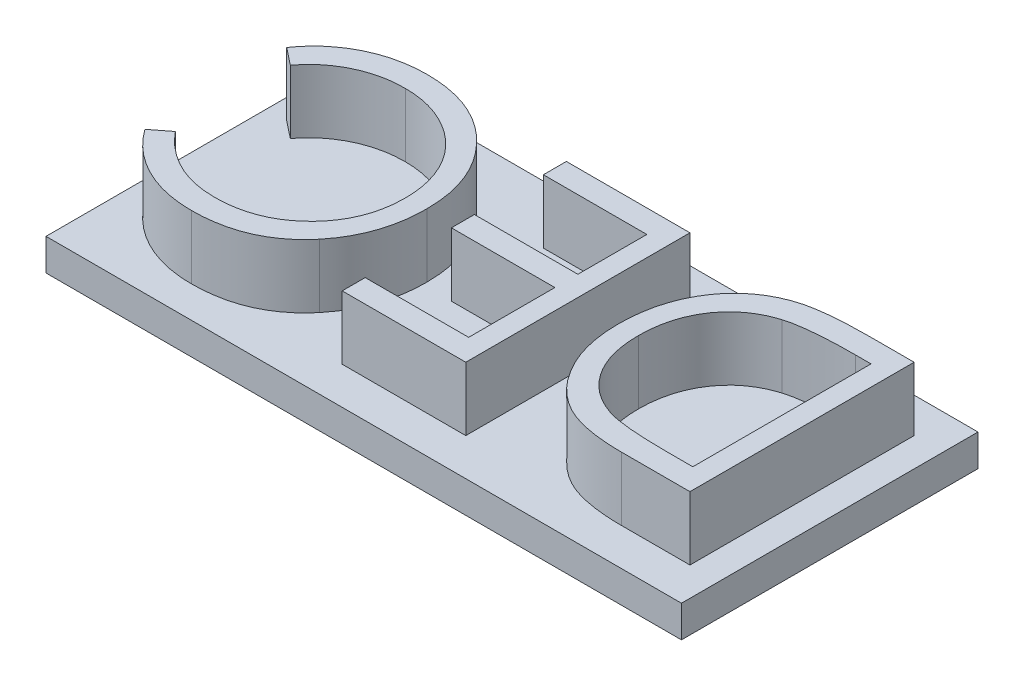
from build123d import *

# Parameters (mm, degrees)
SKETCH1_W           = 15
SKETCH1_H           = 7
BOSS_EXTRUDE1_DEPTH = 0.75
BOSS_EXTRUDE2_DEPTH = 1.5


with BuildPart() as part:
    # Sketch1 → Boss-Extrude1 (new body)
    with BuildSketch(Plane(origin=(0, 0, 0), x_dir=(1, 0, 0), z_dir=(0, 1, 0))):
        Rectangle(SKETCH1_W, SKETCH1_H)
    extrude(amount=BOSS_EXTRUDE1_DEPTH)

    # Sketch2 → Boss-Extrude2 (add)
    with BuildSketch(Plane(origin=(0, 0.75, 0), x_dir=(1, 0, 0), z_dir=(0, 1, 0))):
        with BuildLine():
            Line((6.819807811, -2.619170324), (6.819807811, 2.672496343))
            Line((6.819807811, 2.672496343), (5.767198636, 2.672496343))
            add(Edge.make_bspline(
                [(5.767198636, 2.672496343), (5.675676514, 2.671828776), (5.498951689, 2.670539735), (5.243729806, 2.662334987), (5.007894011, 2.647885338), (4.791573229, 2.626555862), (4.594400699, 2.600948259), (4.416776216, 2.568123539), (4.258546118, 2.5301148), (4.161410306, 2.497192755), (4.115672862, 2.481691054)],
                knots=[0, 0, 0, 0, 0.000274566, 0.000530174, 0.000765968, 0.000983251, 0.001182189, 0.001362238, 0.001524979, 0.001669797, 0.001669797, 0.001669797, 0.001669797], degree=3))
            add(Edge.make_bspline(
                [(4.115672862, 2.481691054), (4.055520422, 2.458319777), (3.936272744, 2.411987981), (3.76627177, 2.32521795), (3.60613388, 2.226589303), (3.455207371, 2.11627488), (3.317056863, 1.991131144), (3.186024775, 1.856518497), (3.068014108, 1.707073142), (2.958461251, 1.547424448), (2.86166046, 1.376929879), (2.776022147, 1.198397052), (2.705478495, 1.011225192), (2.646833603, 0.81647182), (2.601439929, 0.613449091), (2.568587015, 0.402447458), (2.549360783, 0.183554722), (2.546978409, 0.035181062), (2.54576935, -0.040118842)],
                knots=[0, 0, 0, 0, 0.000193501, 0.000383601, 0.000571589, 0.000757312, 0.000943497, 0.001130173, 0.001320223, 0.00151398, 0.001710543, 0.001907788, 0.002107415, 0.002309972, 0.002517505, 0.002730995, 0.002950193, 0.003176069, 0.003176069, 0.003176069, 0.003176069], degree=3))
            add(Edge.make_bspline(
                [(2.54576935, -0.040118842), (2.546886805, -0.105509325), (2.549088381, -0.234339574), (2.563530317, -0.424552304), (2.590623148, -0.608458708), (2.62649015, -0.786499571), (2.671631565, -0.959313486), (2.729422293, -1.125382844), (2.795848778, -1.286165643), (2.873506623, -1.439484576), (2.958757925, -1.584822342), (3.050608363, -1.721328393), (3.147139687, -1.84876971), (3.252409588, -1.964689498), (3.36202299, -2.072282743), (3.479281975, -2.168598215), (3.601571669, -2.256139355), (3.730944304, -2.334410146), (3.870381936, -2.403212936), (4.022430082, -2.461056213), (4.187708678, -2.509630202), (4.365884831, -2.549448147), (4.556931607, -2.581405265), (4.761191642, -2.602882483), (4.978683405, -2.617246889), (5.128329305, -2.618516561), (5.205383065, -2.619170324)],
                knots=[0, 0, 0, 0, 0.000196177, 0.000386502, 0.000571792, 0.000753487, 0.000931158, 0.001107152, 0.001280589, 0.001452673, 0.001622295, 0.001785759, 0.001946045, 0.002101421, 0.002255096, 0.002406428, 0.002556148, 0.002705946, 0.002859544, 0.003021954, 0.003193341, 0.003375925, 0.003569362, 0.003774102, 0.003991844, 0.004222969, 0.004222969, 0.004222969, 0.004222969], degree=3))
            Line((5.205383065, -2.619170324), (6.819807811, -2.619170324))
        make_face()
        with BuildLine():
            Line((6.344914649, -2.076435281), (5.749178137, -2.076435281))
            add(Edge.make_bspline(
                [(5.749178137, -2.076435281), (5.663664961, -2.076061495), (5.499326628, -2.075343158), (5.262884722, -2.069001075), (5.046570259, -2.058628627), (4.850692286, -2.044252646), (4.675728258, -2.025101342), (4.520996704, -2.003490784), (4.386529759, -1.977125293), (4.304923513, -1.952963669), (4.267257063, -1.94181155)],
                knots=[0, 0, 0, 0, 0.000256536, 0.000493008, 0.000709514, 0.00090618, 0.001082122, 0.00123743, 0.001374846, 0.001492643, 0.001492643, 0.001492643, 0.001492643], degree=3))
            add(Edge.make_bspline(
                [(4.267257063, -1.94181155), (4.220004494, -1.924808365), (4.126623293, -1.89120643), (3.992159255, -1.829626807), (3.866233732, -1.756929143), (3.746510039, -1.676738186), (3.63604659, -1.585126105), (3.534383512, -1.483367767), (3.437827482, -1.374435663), (3.351674731, -1.25412773), (3.272929408, -1.12680626), (3.206415933, -0.991094264), (3.148879988, -0.849466214), (3.100710183, -0.70090125), (3.065136032, -0.544708676), (3.040159943, -0.382075273), (3.023469716, -0.212895273), (3.021610364, -0.097754665), (3.020662512, -0.039058812)],
                knots=[0, 0, 0, 0, 0.000150617, 0.000297652, 0.000442938, 0.000586415, 0.000729468, 0.000872634, 0.001017626, 0.001165625, 0.001315973, 0.001466251, 0.001618412, 0.001774294, 0.001934232, 0.0020984, 0.002267693, 0.002443738, 0.002443738, 0.002443738, 0.002443738], degree=3))
            add(Edge.make_bspline(
                [(3.020662512, -0.039058812), (3.021571644, 0.022814678), (3.023357134, 0.144331152), (3.040625249, 0.322886563), (3.069445499, 0.494211278), (3.108395651, 0.659113256), (3.159081684, 0.817357004), (3.222306362, 0.968334721), (3.295020744, 1.113142154), (3.380233021, 1.249488267), (3.47406561, 1.378091503), (3.578324846, 1.495979015), (3.691454535, 1.603318562), (3.812119189, 1.701847044), (3.943696907, 1.787213372), (4.08241153, 1.864171403), (4.230986037, 1.929181806), (4.334455368, 1.963775855), (4.387040383, 1.981357187)],
                knots=[0, 0, 0, 0, 0.000185581, 0.000364472, 0.00053752, 0.00070644, 0.000872378, 0.001035378, 0.001197035, 0.00135794, 0.001517163, 0.001674123, 0.001829326, 0.001984612, 0.002140728, 0.002299184, 0.002460092, 0.002626378, 0.002626378, 0.002626378, 0.002626378], degree=3))
            add(Edge.make_bspline(
                [(4.387040383, 1.981357187), (4.4303486, 1.99365159), (4.522876967, 2.019918686), (4.673766458, 2.047958695), (4.84381209, 2.07344535), (5.033332583, 2.094469567), (5.24232195, 2.109784544), (5.470642446, 2.121249788), (5.71873797, 2.128962966), (5.89086249, 2.129488392), (5.980264542, 2.1297613)],
                knots=[0, 0, 0, 0, 0.000134995, 0.000288417, 0.000459919, 0.000650845, 0.000860276, 0.00108848, 0.001336638, 0.001604834, 0.001604834, 0.001604834, 0.001604834], degree=3))
            Line((5.980264542, 2.1297613), (6.344914649, 2.1297613))
            Line((6.344914649, 2.1297613), (6.344914649, -2.076435281))
        make_face(mode=Mode.SUBTRACT)
        Polygon((1.528141144, 2.672496343), (-1.38905971, 2.672496343), (-1.38905971, 2.1297613), (1.053247982, 2.1297613), (1.053247982, 0.501556172), (-1.38905971, 0.501556172), (-1.38905971, -0.041178871), (1.053247982, -0.041178871), (1.053247982, -2.076435281), (-1.38905971, -2.076435281), (-1.38905971, -2.619170324), (1.528141144, -2.619170324), align=None)
        with BuildLine():
            Line((-7.019935779, 1.70150943), (-6.616064585, 1.383500616))
            add(Edge.make_bspline(
                [(-6.616064585, 1.383500616), (-6.587842278, 1.418817444), (-6.531821719, 1.488920447), (-6.441322073, 1.587470349), (-6.346873213, 1.679851962), (-6.248518796, 1.766027962), (-6.145242016, 1.844141744), (-6.038858354, 1.917090757), (-5.927438747, 1.98253946), (-5.77343951, 2.061618059), (-5.572029164, 2.144649694), (-5.318128514, 2.213899211), (-5.053017042, 2.258266678), (-4.872143037, 2.263023995), (-4.780093698, 2.265445061)],
                knots=[0, 0, 0, 0, 0.000135593, 0.000269148, 0.000401078, 0.00053181, 0.000661138, 0.000789327, 0.000918586, 0.001048486, 0.001308524, 0.001570332, 0.001836616, 0.002112568, 0.002112568, 0.002112568, 0.002112568], degree=3))
            add(Edge.make_bspline(
                [(-4.780093698, 2.265445061), (-4.729169218, 2.26484293), (-4.628155316, 2.263648543), (-4.478498594, 2.247611115), (-4.33180866, 2.224877041), (-4.188013274, 2.191794439), (-4.047044592, 2.148838443), (-3.907844832, 2.099000634), (-3.773076752, 2.036131958), (-3.640833869, 1.967126683), (-3.514336135, 1.888744391), (-3.394227937, 1.803907186), (-3.281518189, 1.71263302), (-3.176402064, 1.614497752), (-3.077468936, 1.511142101), (-2.987070316, 1.399741007), (-2.903450073, 1.282795763), (-2.82830749, 1.159175941), (-2.760176961, 1.031427766), (-2.702046361, 0.898790003), (-2.652887392, 0.762055268), (-2.613042545, 0.621355767), (-2.580765749, 0.477050029), (-2.558943085, 0.328587322), (-2.544472559, 0.176416393), (-2.543075911, 0.073338233), (-2.542371676, 0.021362863)],
                knots=[0, 0, 0, 0, 0.000152703, 0.000302902, 0.000451033, 0.000597862, 0.000745084, 0.000892976, 0.001040975, 0.001190814, 0.001340259, 0.001487023, 0.001631716, 0.001774977, 0.001918191, 0.00206057, 0.002204991, 0.002349159, 0.002494259, 0.002639022, 0.002783202, 0.002929827, 0.003077457, 0.003226473, 0.003379738, 0.00353562, 0.00353562, 0.00353562, 0.00353562], degree=3))
            add(Edge.make_bspline(
                [(-2.542371676, 0.021362863), (-2.543907654, -0.056845827), (-2.54692267, -0.210363883), (-2.579460912, -0.435168209), (-2.627906752, -0.650509412), (-2.700469621, -0.855213116), (-2.790094974, -1.05108988), (-2.901345667, -1.236992899), (-3.033491274, -1.411863584), (-3.183413634, -1.575758024), (-3.349092877, -1.724183357), (-3.526160996, -1.85580317), (-3.715284619, -1.964847367), (-3.913621832, -2.056214392), (-4.123121423, -2.125942125), (-4.343294285, -2.175415374), (-4.573506616, -2.207433237), (-4.730870856, -2.210540238), (-4.81083455, -2.212119042)],
                knots=[0, 0, 0, 0, 0.000234461, 0.00046023, 0.000680075, 0.000895637, 0.001110488, 0.001325368, 0.001544159, 0.001766989, 0.001990678, 0.002210537, 0.002427617, 0.002644395, 0.002864629, 0.003088607, 0.003320678, 0.003560435, 0.003560435, 0.003560435, 0.003560435], degree=3))
            add(Edge.make_bspline(
                [(-4.81083455, -2.212119042), (-4.898985141, -2.209563315), (-5.072748625, -2.204525435), (-5.327760734, -2.161789031), (-5.57191223, -2.093123971), (-5.804704864, -1.995948572), (-6.025873114, -1.870311575), (-6.236298162, -1.717922143), (-6.436276966, -1.538145325), (-6.555316022, -1.400445969), (-6.616064585, -1.330174597)],
                knots=[0, 0, 0, 0, 0.000264307, 0.000521005, 0.000773341, 0.001023752, 0.001275803, 0.001534704, 0.001801886, 0.002080335, 0.002080335, 0.002080335, 0.002080335], degree=3))
            Line((-6.616064585, -1.330174597), (-7.019935779, -1.645003323))
            add(Edge.make_bspline(
                [(-7.019935779, -1.645003323), (-6.98791241, -1.688136374), (-6.924057516, -1.774144079), (-6.820307487, -1.895568512), (-6.710708677, -2.009305561), (-6.59557678, -2.116129028), (-6.474254914, -2.215417908), (-6.346489889, -2.306638622), (-6.213618429, -2.390885819), (-6.075079376, -2.466737936), (-5.931755326, -2.535296438), (-5.783300564, -2.592921492), (-5.631218153, -2.643068947), (-5.474903564, -2.684761896), (-5.314096656, -2.716347147), (-5.149099852, -2.73822148), (-4.980348318, -2.752782828), (-4.866340278, -2.754158663), (-4.808714491, -2.754854085)],
                knots=[0, 0, 0, 0, 0.000161128, 0.000321291, 0.000478726, 0.000634748, 0.000792194, 0.000948691, 0.001105439, 0.001263895, 0.001422265, 0.001581711, 0.001741273, 0.001902488, 0.00206672, 0.002232526, 0.002401633, 0.00257447, 0.00257447, 0.00257447, 0.00257447], degree=3))
            add(Edge.make_bspline(
                [(-4.808714491, -2.754854085), (-4.753918661, -2.754474182), (-4.645962168, -2.753725714), (-4.486179349, -2.740857741), (-4.330745536, -2.723778169), (-4.179860076, -2.697626195), (-4.032989555, -2.666713844), (-3.891130831, -2.6255948), (-3.753089997, -2.579670259), (-3.619912297, -2.524847117), (-3.490735512, -2.463954792), (-3.366133396, -2.394272103), (-3.245694813, -2.318375244), (-3.129515729, -2.235297377), (-3.018096875, -2.144950096), (-2.910912901, -2.047563463), (-2.808740314, -1.941961457), (-2.744470057, -1.867230715), (-2.711976377, -1.829448436)],
                knots=[0, 0, 0, 0, 0.000164335, 0.000323767, 0.00048063, 0.000633289, 0.000782989, 0.000930634, 0.001076117, 0.001219225, 0.001362419, 0.001504297, 0.001647224, 0.001789304, 0.001932506, 0.002077327, 0.002223507, 0.002372987, 0.002372987, 0.002372987, 0.002372987], degree=3))
            add(Edge.make_bspline(
                [(-2.711976377, -1.829448436), (-2.660581952, -1.763543302), (-2.558212332, -1.63227063), (-2.426972032, -1.420577354), (-2.316341136, -1.198524458), (-2.224475652, -0.967219895), (-2.154973862, -0.724871089), (-2.103678305, -0.473337898), (-2.073905191, -0.211144735), (-2.069645001, -0.033126121), (-2.067478514, 0.057403861)],
                knots=[0, 0, 0, 0, 0.000250591, 0.000499138, 0.000745649, 0.000994067, 0.001244658, 0.001500986, 0.001763437, 0.002035011, 0.002035011, 0.002035011, 0.002035011], degree=3))
            add(Edge.make_bspline(
                [(-2.067478514, 0.057403861), (-2.070041509, 0.1525583), (-2.075081483, 0.339673711), (-2.111314698, 0.61464466), (-2.173399389, 0.877402847), (-2.257669659, 1.129482472), (-2.369547049, 1.36874683), (-2.502637483, 1.598243257), (-2.663789187, 1.81371555), (-2.844565425, 2.01745347), (-3.044343825, 2.202546441), (-3.258344155, 2.365302197), (-3.485990694, 2.501383516), (-3.724969622, 2.614499882), (-3.976938326, 2.701991219), (-4.241375455, 2.762857951), (-4.51786449, 2.800972107), (-4.706473383, 2.80575081), (-4.802354315, 2.808180103)],
                knots=[0, 0, 0, 0, 0.000285431, 0.000561284, 0.000830233, 0.001094382, 0.001357135, 0.001621295, 0.001888853, 0.002162893, 0.00243743, 0.002704559, 0.002967978, 0.003231627, 0.003496465, 0.003766446, 0.00404454, 0.004332089, 0.004332089, 0.004332089, 0.004332089], degree=3))
            add(Edge.make_bspline(
                [(-4.802354315, 2.808180103), (-4.86068238, 2.80745307), (-4.976092958, 2.806014527), (-5.147067905, 2.791903262), (-5.314011435, 2.768335951), (-5.476511035, 2.736878596), (-5.635027278, 2.696702986), (-5.788349425, 2.645365334), (-5.938097697, 2.586031143), (-6.083384494, 2.518345168), (-6.22303219, 2.44192554), (-6.356908621, 2.358599998), (-6.48300763, 2.26632002), (-6.604864305, 2.169690074), (-6.717605513, 2.062428819), (-6.826772694, 1.950663336), (-6.927167152, 1.829446097), (-6.988943244, 1.744251053), (-7.019935779, 1.70150943)],
                knots=[0, 0, 0, 0, 0.000174956, 0.000346176, 0.000514227, 0.00068054, 0.000842513, 0.00100442, 0.001165241, 0.00132553, 0.001484916, 0.001642561, 0.001798198, 0.001953484, 0.00210873, 0.002264666, 0.002421969, 0.00258034, 0.00258034, 0.00258034, 0.00258034], degree=3))
        make_face()
    extrude(amount=BOSS_EXTRUDE2_DEPTH)


solid = part.part
